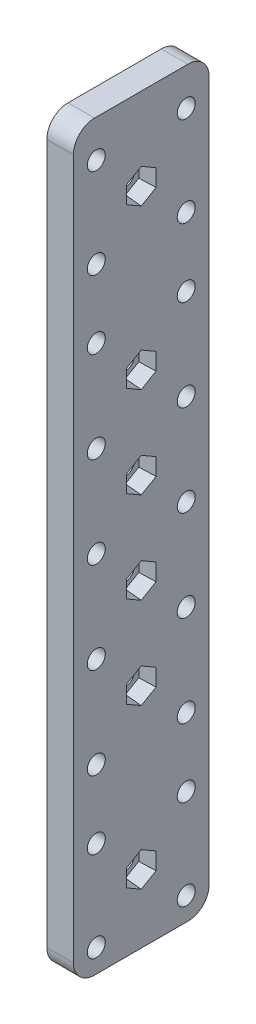
from build123d import *

# Parameters (mm, degrees)
ESQUISSE2_R             = 1.7
BOSS_EXTRU_1_DEPTH      = 5
ENL_V_MAT_EXTRU_1_DEPTH = 3
ENL_V_MAT_EXTRU_1_TAPER = 5


with BuildPart() as part:
    # Esquisse2 → Boss.-Extru.1 (new body)
    with BuildSketch(Plane(origin=(0, 0, 0), x_dir=(0, 0, -1), z_dir=(1, 0, 0))):
        with BuildLine():
            Line((-25.6, -133.893899255), (-25.6, -1.893899255))
            ThreePointArc((-25.6, -1.893899255), (-24.428427125, 0.93452787), (-21.6, 2.106100745))
            Line((-21.6, 2.106100745), (-4.004577751, 2.106100745))
            ThreePointArc((-4.004577751, 2.106100745), (-1.176198229, 0.934575472), (-0.004577753, -1.893764615))
            Line((-0.004577753, -1.893764615), (-0.000134644, -133.893764615))
            ThreePointArc((-0.000134644, -133.893764615), (-1.171659915, -136.722278777), (-4.000134642, -137.893899255))
            Line((-4.000134642, -137.893899255), (-21.6, -137.893899255))
            ThreePointArc((-21.6, -137.893899255), (-24.428427125, -136.72232638), (-25.6, -133.893899255))
        make_face()
        with Locations((-21.285281374, -103.629375049)):
            Circle(ESQUISSE2_R, mode=Mode.SUBTRACT)
        with Locations((-4.314718626, -103.629375049)):
            Circle(ESQUISSE2_R, mode=Mode.SUBTRACT)
        with Locations((-4.314718626, -86.427328272)):
            Circle(ESQUISSE2_R, mode=Mode.SUBTRACT)
        with Locations((-21.285281374, -86.427328272)):
            Circle(ESQUISSE2_R, mode=Mode.SUBTRACT)
        with Locations((-21.285281374, -133.513633034)):
            Circle(ESQUISSE2_R, mode=Mode.SUBTRACT)
        with Locations((-4.314718626, -133.513633034)):
            Circle(ESQUISSE2_R, mode=Mode.SUBTRACT)
        with Locations((-4.314718626, -69.225281495)):
            Circle(ESQUISSE2_R, mode=Mode.SUBTRACT)
        with Locations((-21.285281374, -69.225281495)):
            Circle(ESQUISSE2_R, mode=Mode.SUBTRACT)
        with Locations((-4.314718626, -52.023234718)):
            Circle(ESQUISSE2_R, mode=Mode.SUBTRACT)
        with Locations((-21.285281374, -52.023234718)):
            Circle(ESQUISSE2_R, mode=Mode.SUBTRACT)
        with Locations((-4.314718626, -34.821187941)):
            Circle(ESQUISSE2_R, mode=Mode.SUBTRACT)
        with Locations((-21.285281374, -34.821187941)):
            Circle(ESQUISSE2_R, mode=Mode.SUBTRACT)
        with Locations((-21.285281374, -4.936929955)):
            Circle(ESQUISSE2_R, mode=Mode.SUBTRACT)
        with Locations((-4.314718626, -4.936929955)):
            Circle(ESQUISSE2_R, mode=Mode.SUBTRACT)
        with Locations((-4.314718626, -116.543070286)):
            Circle(ESQUISSE2_R, mode=Mode.SUBTRACT)
        with Locations((-21.285281374, -116.543070286)):
            Circle(ESQUISSE2_R, mode=Mode.SUBTRACT)
        with Locations((-4.314718626, -21.907492704)):
            Circle(ESQUISSE2_R, mode=Mode.SUBTRACT)
        with Locations((-21.285281374, -21.907492704)):
            Circle(ESQUISSE2_R, mode=Mode.SUBTRACT)
        with Locations((-12.8, -13.422211329)):
            Circle(ESQUISSE2_R, mode=Mode.SUBTRACT)
        with Locations((-12.8, -43.422211329)):
            Circle(ESQUISSE2_R, mode=Mode.SUBTRACT)
        with Locations((-12.8, -60.624258106)):
            Circle(ESQUISSE2_R, mode=Mode.SUBTRACT)
        with Locations((-12.8, -77.826304883)):
            Circle(ESQUISSE2_R, mode=Mode.SUBTRACT)
        with Locations((-12.8, -95.02835166)):
            Circle(ESQUISSE2_R, mode=Mode.SUBTRACT)
        with Locations((-12.8, -125.02835166)):
            Circle(ESQUISSE2_R, mode=Mode.SUBTRACT)
    extrude(amount=BOSS_EXTRU_1_DEPTH)

    # Esquisse3 → Enlèv. mat.-Extru.1 (cut)
    with BuildSketch(Plane(origin=(5, 0, 0), x_dir=(0, 0, -1), z_dir=(1, 0, 0))):
        Polygon((-12.8, -10.189049822), (-15.6, -11.805630576), (-15.6, -15.038792083), (-12.8, -16.655372837), (-10, -15.038792083), (-10, -11.805630576), align=None)
        Polygon((-12.8, -40.189049822), (-15.6, -41.805630576), (-15.6, -45.038792083), (-12.8, -46.655372837), (-10, -45.038792083), (-10, -41.805630576), align=None)
        Polygon((-12.8, -57.391096599), (-15.6, -59.007677352), (-15.6, -62.24083886), (-12.8, -63.857419614), (-10, -62.24083886), (-10, -59.007677352), align=None)
        Polygon((-12.8, -74.593143376), (-15.6, -76.209724129), (-15.6, -79.442885637), (-12.8, -81.059466391), (-10, -79.442885637), (-10, -76.209724129), align=None)
        Polygon((-12.8, -91.795190153), (-15.6, -93.411770906), (-15.6, -96.644932414), (-12.8, -98.261513168), (-10, -96.644932414), (-10, -93.411770906), align=None)
        Polygon((-12.8, -121.795190153), (-15.6, -123.411770906), (-15.6, -126.644932414), (-12.8, -128.261513168), (-10, -126.644932414), (-10, -123.411770906), align=None)
    extrude(amount=-ENL_V_MAT_EXTRU_1_DEPTH, taper=ENL_V_MAT_EXTRU_1_TAPER, mode=Mode.SUBTRACT)


solid = part.part
